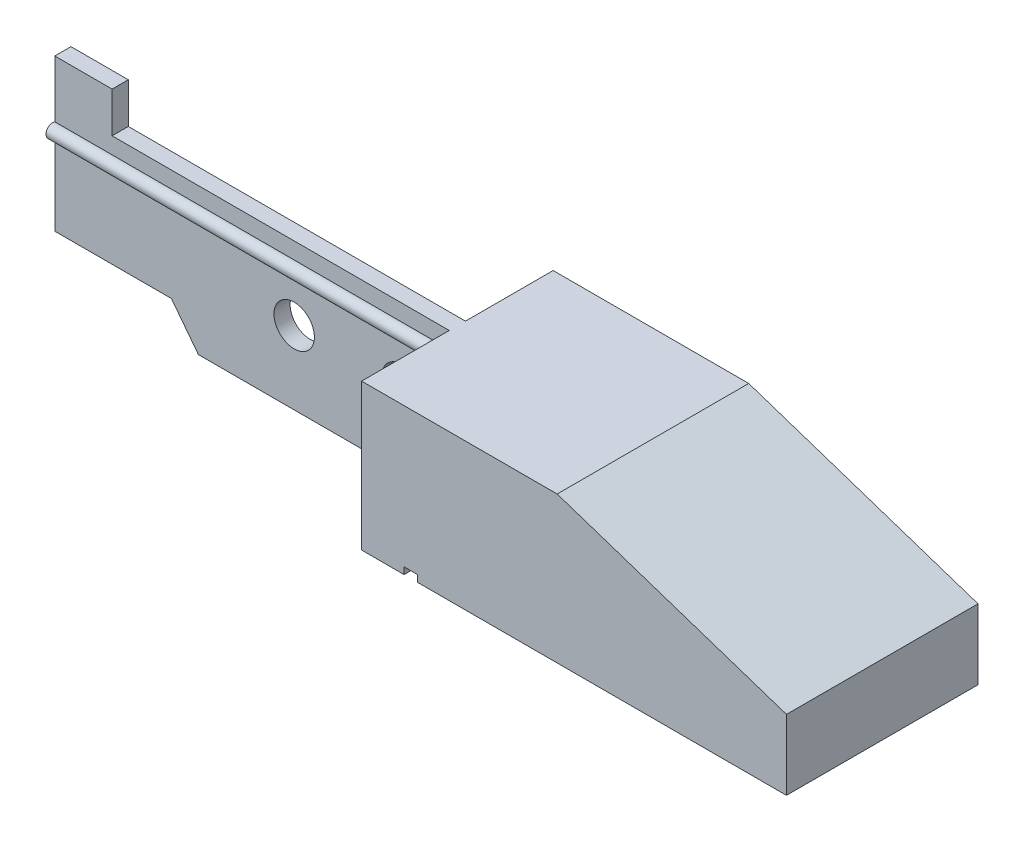
from build123d import *

# Parameters (mm, degrees)
DODANIE_WYCI_GNI_CIE1_DEPTH = 14.2
SZKIC2_W                    = 1.2
SZKIC2_H                    = 10.85
DODANIE_WYCI_GNI_CIE3_DEPTH = 29.25
SZKIC6_W                    = 4.251450278
SZKIC6_H                    = 1.2
DODANIE_WYCI_GNI_CIE4_DEPTH = 3
SZKIC20_R                   = 1.5
WYTNIJ_WYCI_GNI_CIE5_DEPTH  = 10
WYTNIJ_WYCI_GNI_CIE3_DEPTH  = 0.5
SZKIC11_R                   = 0.5
DODANIE_WYCI_GNI_CIE5_DEPTH = 29.25
WYTNIJ_WYCI_GNI_CIE6_DEPTH  = 10
SZKIC23_R                   = 1.5
WYTNIJ_WYCI_GNI_CIE8_DEPTH  = 10


with BuildPart() as part:
    # Szkic1 → Dodanie-wyciągnięcie1 (new body)
    with BuildSketch(Plane.XY):
        Polygon((-36.878659539, 9.21375), (-5.378659539, 9.21375), (-5.378659539, 14.41375), (-22.378659539, 20.06375), (-36.878659539, 20.06375), align=None)
    extrude(amount=DODANIE_WYCI_GNI_CIE1_DEPTH)

    # Szkic2 → Dodanie-wyciągnięcie3 (add)
    with BuildSketch(Plane.ZY.offset(36.878659539)):
        with Locations((7.1, 14.63875)):
            Rectangle(SZKIC2_W, SZKIC2_H)
    extrude(amount=DODANIE_WYCI_GNI_CIE3_DEPTH)

    # Szkic6 → Dodanie-wyciągnięcie4 (add)
    with BuildSketch(Plane(origin=(0, 20.06375, 0), x_dir=(1, 0, 0), z_dir=(0, 1, 0))):
        with Locations((-64.0029344, -7.1)):
            Rectangle(SZKIC6_W, SZKIC6_H)
    extrude(amount=DODANIE_WYCI_GNI_CIE4_DEPTH)

    # Szkic20 → Wytnij-wyciągnięcie5 (cut)
    with BuildSketch(Plane.XY.offset(7.7)):
        with Locations((-40.378659539, 14.63375)):
            Circle(SZKIC20_R)
    extrude(amount=-WYTNIJ_WYCI_GNI_CIE5_DEPTH, mode=Mode.SUBTRACT)

    # Szkic10 → Wytnij-wyciągnięcie3 (cut)
    with BuildSketch(Plane.XZ.offset(-9.21375)):
        Polygon((-33.729246345, 6.369364803), (-33.729246345, 14.2), (-32.729246345, 14.2), (-32.729246345, 0), (-33.729246345, 0), align=None)
    extrude(amount=-WYTNIJ_WYCI_GNI_CIE3_DEPTH, mode=Mode.SUBTRACT)

    # Szkic11 → Dodanie-wyciągnięcie5 (add)
    with BuildSketch(Plane.ZY.offset(36.878659539)):
        with Locations((7.85, 18.36375)):
            Circle(SZKIC11_R)
    extrude(amount=DODANIE_WYCI_GNI_CIE5_DEPTH)

    # Szkic21 → Wytnij-wyciągnięcie6 (cut)
    with BuildSketch(Plane(origin=(0, 0, 6.5), x_dir=(-1, 0, 0), z_dir=(0, 0, -1))):
        Polygon((55.478659539, 9.21375), (66.128659539, 9.21375), (66.128659539, 11.81375), (57.478659539, 11.81375), align=None)
    extrude(amount=-WYTNIJ_WYCI_GNI_CIE6_DEPTH, mode=Mode.SUBTRACT)

    # Szkic23 → Wytnij-wyciągnięcie8 (cut)
    with BuildSketch(Plane(origin=(0, 0, 6.5), x_dir=(-1, 0, 0), z_dir=(0, 0, -1))):
        with Locations((48.378659539, 14.63375)):
            Circle(SZKIC23_R)
    extrude(amount=-WYTNIJ_WYCI_GNI_CIE8_DEPTH, mode=Mode.SUBTRACT)


solid = part.part
